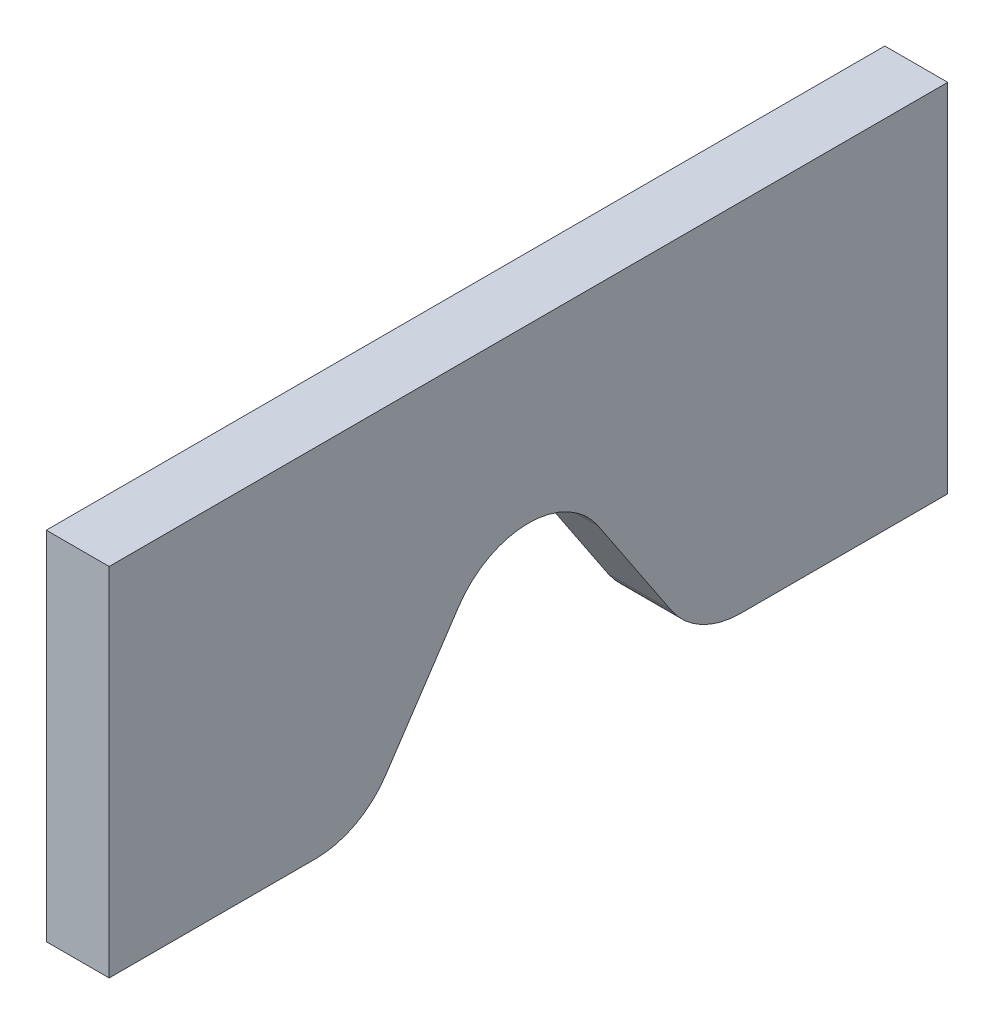
from build123d import *

# Parameters (mm, degrees)
BOSS_EXTRUDE1_DEPTH = 19.05


with BuildPart() as part:
    # Sketch1 → Boss-Extrude1 (new body)
    with BuildSketch(Plane(origin=(0, 0, 0), x_dir=(0, 0, -1), z_dir=(1, 0, 0))):
        with BuildLine():
            Line((-127, 0), (-127, 107.95))
            Line((-127, 107.95), (127, 107.95))
            Line((127, 107.95), (127, 0))
            Line((127, 0), (64.393667466, 0))
            ThreePointArc((64.393667466, 0), (52.408476157, 3.005465191), (43.259589989, 11.310615016))
            Line((43.259589989, 11.310615016), (21.134077476, 44.498883786))
            ThreePointArc((21.134077476, 44.498883786), (0, 55.809498802), (-21.134077476, 44.498883786))
            Line((-21.134077476, 44.498883786), (-43.259589989, 11.310615016))
            ThreePointArc((-43.259589989, 11.310615016), (-52.408476157, 3.005465191), (-64.393667466, 0))
            Line((-64.393667466, 0), (-127, 0))
        make_face()
    extrude(amount=BOSS_EXTRUDE1_DEPTH)


solid = part.part
